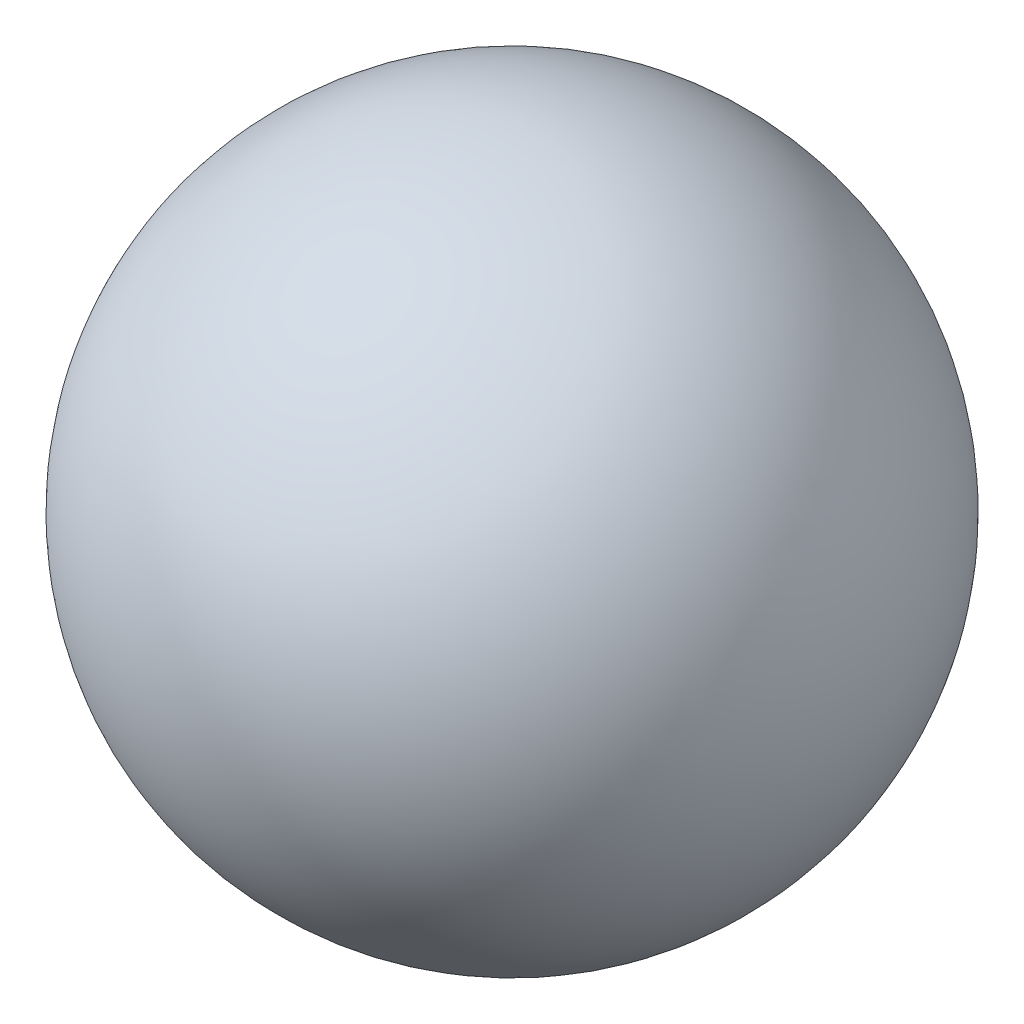
from build123d import *


with BuildPart() as part:
    # Sketch1 → Revolve1 (revolve)
    with BuildSketch(Plane.XY):
        with BuildLine():
            Line((5.882, 10), (1.118, 10))
            ThreePointArc((1.118, 10), (3.5, 12.382), (5.882, 10))
        make_face()
    revolve(axis=Axis((50, 10, 0), (-1, 0, 0)))


solid = part.part
